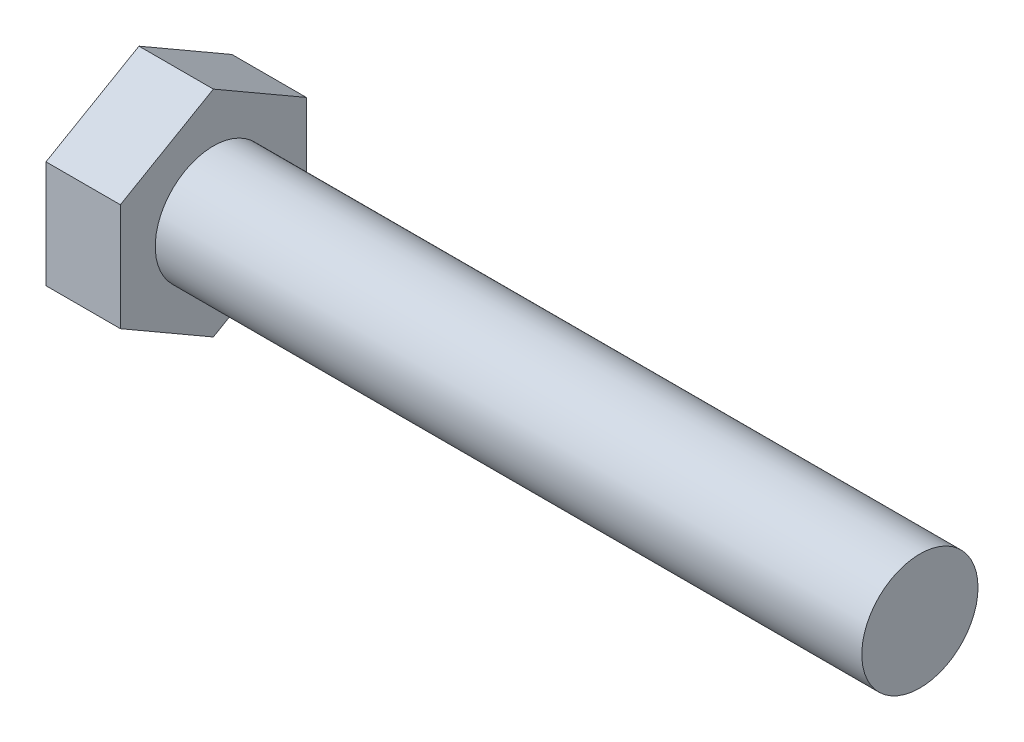
from build123d import *

# Parameters (mm, degrees)
BOSS_EXTRUDE1_DEPTH = 5.08
SKETCH2_R           = 3.96875
BOSS_EXTRUDE2_DEPTH = 48.26


with BuildPart() as part:
    # Sketch1 → Boss-Extrude1 (new body)
    with BuildSketch(Plane(origin=(0, 0, 0), x_dir=(0, 0, -1), z_dir=(1, 0, 0))):
        Polygon((6.35, 3.666174209), (0, 7.332348419), (-6.35, 3.666174209), (-6.35, -3.666174209), (0, -7.332348419), (6.35, -3.666174209), align=None)
    extrude(amount=BOSS_EXTRUDE1_DEPTH)

    # Sketch2 → Boss-Extrude2 (add)
    with BuildSketch(Plane(origin=(5.08, 0, 0), x_dir=(0, 0, -1), z_dir=(1, 0, 0))):
        Circle(SKETCH2_R)
    extrude(amount=BOSS_EXTRUDE2_DEPTH)


solid = part.part
